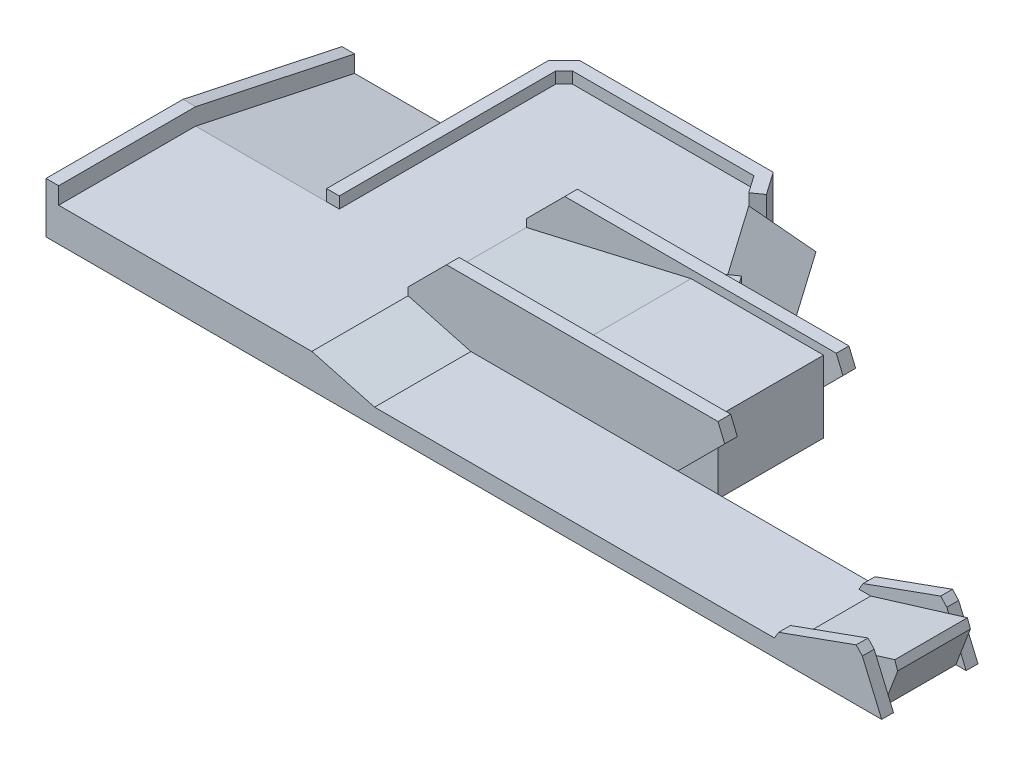
from build123d import *

# Parameters (mm, degrees)
EXTRUDE_2_DEPTH      = 400
EXTRUDE_21_DEPTH     = 1700
SKETCH_8_W           = 3517
SKETCH_8_H           = 1550
EXTRUDE_3_DEPTH      = 850
CUT_EXTRUDE_1_DEPTH  = 5979.702952982
SKETCH_10_W          = 5615.18
SKETCH_10_H          = 1140
EXTRUDE_4_DEPTH      = 200
EXTRUDE_5_DEPTH      = 1140
EXTRUDE_6_DEPTH      = 140
EXTRUDE_10_DEPTH     = 150
EXTRUDE_11_DEPTH     = 535
CUT_EXTRUDE_START    = -1550
CUT_EXTRUDE_8_DEPTH  = 150
EXTRUDE_12_DEPTH     = 150
EXTRUDE_START        = -1400
EXTRUDE_13_DEPTH     = 150
CUT_EXTRUDE_9_DEPTH  = 150
CUT_EXTRUDE_10_DEPTH = 150
CUT_EXTRUDE_11_DEPTH = 9020.061936414
EXTRUDE_14_DEPTH     = 1200
EXTRUDE_18_DEPTH     = 860
EXTRUDE_START_2      = -1000
EXTRUDE_20_DEPTH     = 140


with BuildPart() as part:
    # 草图1 → 凸台-拉伸2 (new body)
    with BuildSketch(Plane(origin=(0, 0, 0), x_dir=(1, 0, 0), z_dir=(0, 1, 0))):
        Polygon((-1498, -810.5), (1498, -810.5), (1498, 1879.5), (3563.73040083, 1879.5), (2449, 3471.5), (202, 3471.5), (202, 810.5), (-1498, 810.5), align=None)
    extrude(amount=EXTRUDE_2_DEPTH)

    # 草图2 → 凸台-拉伸21 (add)
    with BuildSketch(Plane.ZY.offset(-202)):
        Polygon((-810.5, 0), (-2692.348222387, 0), (-810.5, 400), align=None)
    extrude(amount=EXTRUDE_21_DEPTH)

    # 草图8 → 凸台-拉伸3 (add)
    with BuildSketch(Plane(origin=(0, 0, 0), x_dir=(1, 0, 0), z_dir=(0, 1, 0))):
        with Locations((3256.5, 1104.5)):
            Rectangle(SKETCH_8_W, SKETCH_8_H)
    extrude(amount=EXTRUDE_3_DEPTH)

    # 草图9 → 切除-拉伸1 (cut, through all)
    with BuildSketch(Plane.XY.offset(-329.5)):
        Polygon((3447, 850), (1498, 400), (1498, 850), align=None)
    extrude(amount=-CUT_EXTRUDE_1_DEPTH, mode=Mode.SUBTRACT)

    # 草图10 → 凸台-拉伸4 (add)
    with BuildSketch(Plane(origin=(0, 0, 0), x_dir=(1, 0, 0), z_dir=(0, 1, 0))):
        with Locations((4305.59, -240.5)):
            Rectangle(SKETCH_10_W, SKETCH_10_H)
    extrude(amount=EXTRUDE_4_DEPTH)

    # 草图11 → 凸台-拉伸5 (add)
    with BuildSketch(Plane.XY.offset(-329.5)):
        Polygon((1498, 400), (1498, 200), (2240.68, 200), align=None)
    extrude(amount=EXTRUDE_5_DEPTH)

    # 草图13<4> → 凸台-拉伸6 (add)
    with BuildSketch(Plane(origin=(0, 0, -329.5), x_dir=(-1, 0, 0), z_dir=(0, 0, -1))):
        Polygon((-6853.029478436, 0), (-7023.093186264, 283.084427124), (-7940.882052173, 613.635251678), (-8013.69202852, 535.173356822), (-8242.693186264, 0), align=None)
    extrude(amount=-EXTRUDE_6_DEPTH)

    # 草图16 → 凸台-拉伸10 (add)
    with BuildSketch(Plane.ZY.offset(1498)):
        Polygon((-810.5, 600), (-2692.348222387, 200), (-2692.348222387, 0), (810.5, 0), (810.5, 600), align=None)
    extrude(amount=EXTRUDE_10_DEPTH)

    # 草图17 → 凸台-拉伸11 (add)
    with BuildSketch(Plane(origin=(0, 0, 0), x_dir=(1, 0, 0), z_dir=(0, 1, 0))):
        Polygon((202, 810.5), (52, 810.5), (52, 3433.632034356), (239.867965644, 3621.5), (2527.085057583, 3621.5), (3746.846589144, 1879.5), (3563.73040083, 1879.5), (2449, 3471.5), (302, 3471.5), (202, 3371.5), align=None)
    extrude(amount=EXTRUDE_11_DEPTH)

    # 草图18<2> → 切除-拉伸8 (cut)
    with BuildSketch(Plane(origin=(0, 0, -1879.5), x_dir=(-1, 0, 0), z_dir=(0, 0, -1)).offset(CUT_EXTRUDE_START)):
        Polygon((-4489.875994157, 0), (-5244.44, 754.585712816), (-5165.54937105, 945), (-1952.16937105, 945), (-1498, 490.82), (-1498, 0), align=None)
    extrude(amount=CUT_EXTRUDE_8_DEPTH, mode=Mode.SUBTRACT)

    # 草图18<3> → 凸台-拉伸12 (add)
    with BuildSketch(Plane(origin=(0, 0, -1879.5), x_dir=(-1, 0, 0), z_dir=(0, 0, -1))):
        Polygon((-4489.875994157, 0), (-5244.44, 754.585712816), (-5165.54937105, 945), (-1952.16937105, 945), (-1498, 490.82), (-1498, 0), align=None)
    extrude(amount=-EXTRUDE_12_DEPTH)

    # 草图18 → 凸台-拉伸13 (add)
    with BuildSketch(Plane(origin=(0, 0, -1879.5), x_dir=(-1, 0, 0), z_dir=(0, 0, -1)).offset(EXTRUDE_START)):
        Polygon((-4489.875994157, 0), (-5244.44, 754.585712816), (-5165.54937105, 945), (-1952.16937105, 945), (-1498, 490.82), (-1498, 0), align=None)
    extrude(amount=-EXTRUDE_13_DEPTH)

    # 草图19 → 切除-拉伸9 (cut)
    with BuildSketch(Plane(origin=(0, 0, -1879.5), x_dir=(-1, 0, 0), z_dir=(0, 0, -1))):
        Polygon((-5015, 525.139112385), (-4489.875994157, 0), (-5015, 0), align=None)
    extrude(amount=-CUT_EXTRUDE_9_DEPTH, mode=Mode.SUBTRACT)

    # 草图19<2> → 切除-拉伸10 (cut)
    with BuildSketch(Plane(origin=(0, 0, -1879.5), x_dir=(-1, 0, 0), z_dir=(0, 0, -1)).offset(CUT_EXTRUDE_START)):
        Polygon((-5015, 525.139112385), (-4489.875994157, 0), (-5015, 0), align=None)
    extrude(amount=CUT_EXTRUDE_10_DEPTH, mode=Mode.SUBTRACT)

    # 草图20 → 切除-拉伸11 (cut, through all)
    with BuildSketch(Plane(origin=(0, 535, 0), x_dir=(1, 0, 0), z_dir=(0, 1, 0))):
        Polygon((2592.394109088, 3266.711988928), (3165.80054009, 3668.215494373), (3854.092263711, 2685.233041227), (3280.685832709, 2283.729535781), align=None)
    extrude(amount=-CUT_EXTRUDE_11_DEPTH, mode=Mode.SUBTRACT)

    # 草图21 → 凸台-拉伸14 (add)
    with BuildSketch(Plane(origin=(6.310700678, 0, 9.012614594), x_dir=(-0.8191520442889888, 0, 0.5735764363510504), z_dir=(-0.5735764363510504, 0, -0.8191520442889888))):
        Polygon((-3997.273955256, 400), (-3997.273955256, 0), (-4568.533157953, 0), align=None)
    extrude(amount=EXTRUDE_14_DEPTH)

    # 草图15 → 凸台-拉伸18 (add)
    with BuildSketch(Plane.XY.offset(-189.5)):
        Polygon((7113.18, 0), (7113.18, 200), (8257.982320097, 550), (8292.2785298, 451.14), (8120.829514638, 0), align=None)
    extrude(amount=EXTRUDE_18_DEPTH)

    # 草图13 → 凸台-拉伸20 (add)
    with BuildSketch(Plane(origin=(0, 0, -329.5), x_dir=(-1, 0, 0), z_dir=(0, 0, -1)).offset(EXTRUDE_START_2)):
        Polygon((-6853.029478436, 0), (-7023.093186264, 283.084427124), (-7940.882052173, 613.635251678), (-8013.69202852, 535.173356822), (-8242.693186264, 0), align=None)
    extrude(amount=-EXTRUDE_20_DEPTH)


solid = part.part
